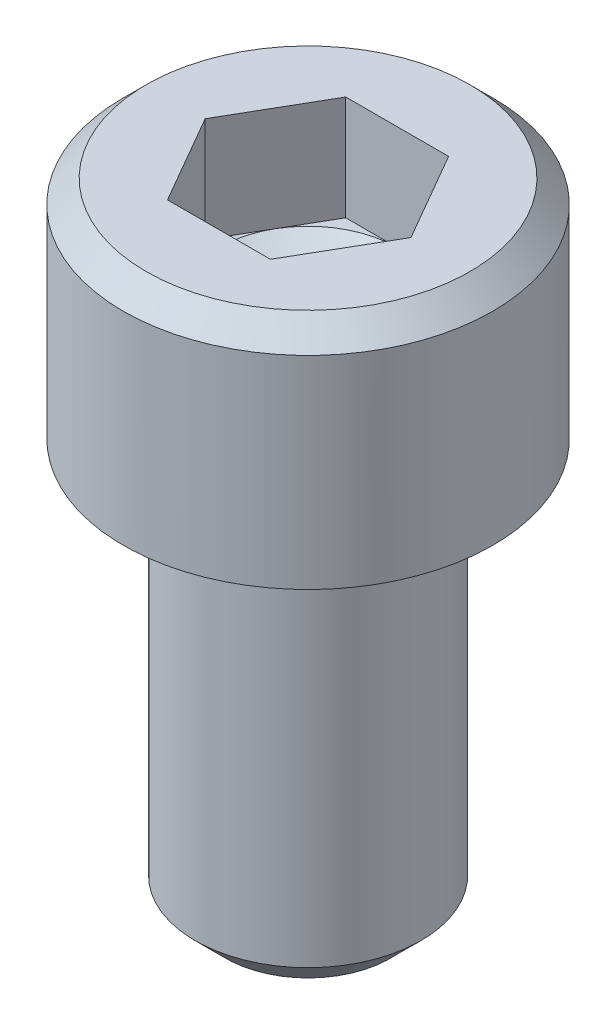
from build123d import *

# Parameters (mm, degrees)
SKETCH1_W           = 2.8702
SKETCH1_H           = 3.5052
SKETCH2_R           = 1.7526
BOSS_EXTRUDE1_DEPTH = 6.35
CUT_EXTRUDE1_DEPTH  = 1.6256
CHAMFER1_SIZE       = 0.47244
CHAMFER2_SIZE       = 0.3556
FILLET1_R           = 0.254


with BuildPart() as part:
    # Sketch1 → Revolve1 (revolve)
    with BuildSketch(Plane.XY):
        with Locations((1.4351, 1.7526)):
            Rectangle(SKETCH1_W, SKETCH1_H)
    revolve(axis=Axis((0, 3.5052, 0), (0, -1, 0)))

    # Sketch2 → Boss-Extrude1 (add)
    with BuildSketch(Plane.XZ):
        Circle(SKETCH2_R)
    extrude(amount=BOSS_EXTRUDE1_DEPTH)

    # Sketch3 → Cut-Extrude1 (cut)
    with BuildSketch(Plane(origin=(0, 3.5052, 0), x_dir=(-1, 0, 0), z_dir=(0, 1, 0))):
        Polygon((-1.598451955, 0), (-0.799225978, -1.3843), (0.799225978, -1.3843), (1.598451955, 0), (0.799225978, 1.3843), (-0.799225978, 1.3843), align=None)
    extrude(amount=-CUT_EXTRUDE1_DEPTH, mode=Mode.SUBTRACT)

    # Sketch4 → Cut-Revolve1 (revolve, cut)
    with BuildSketch(Plane.XY):
        Polygon((1.3843, 1.8796), (0, 1.8796), (0, 1.080374022), align=None)
    revolve(axis=Axis((0, 1.8796, 0), (0, -1, 0)), mode=Mode.SUBTRACT)

    # Chamfer1
    chamfer1_edges = [part.edges().sort_by_distance(p)[0] for p in [
        (-1.7526, -6.35, 0),
    ]]
    chamfer(chamfer1_edges, length=CHAMFER1_SIZE)

    # Chamfer2
    chamfer2_edges = [part.edges().sort_by_distance(p)[0] for p in [
        (-2.8702, 3.5052, 0),
    ]]
    chamfer(chamfer2_edges, length=CHAMFER2_SIZE)

    # Fillet1
    fillet1_edges = [part.edges().sort_by_distance(p)[0] for p in [
        (-1.7526, 0, 0),
    ]]
    fillet(fillet1_edges, radius=FILLET1_R)


solid = part.part
